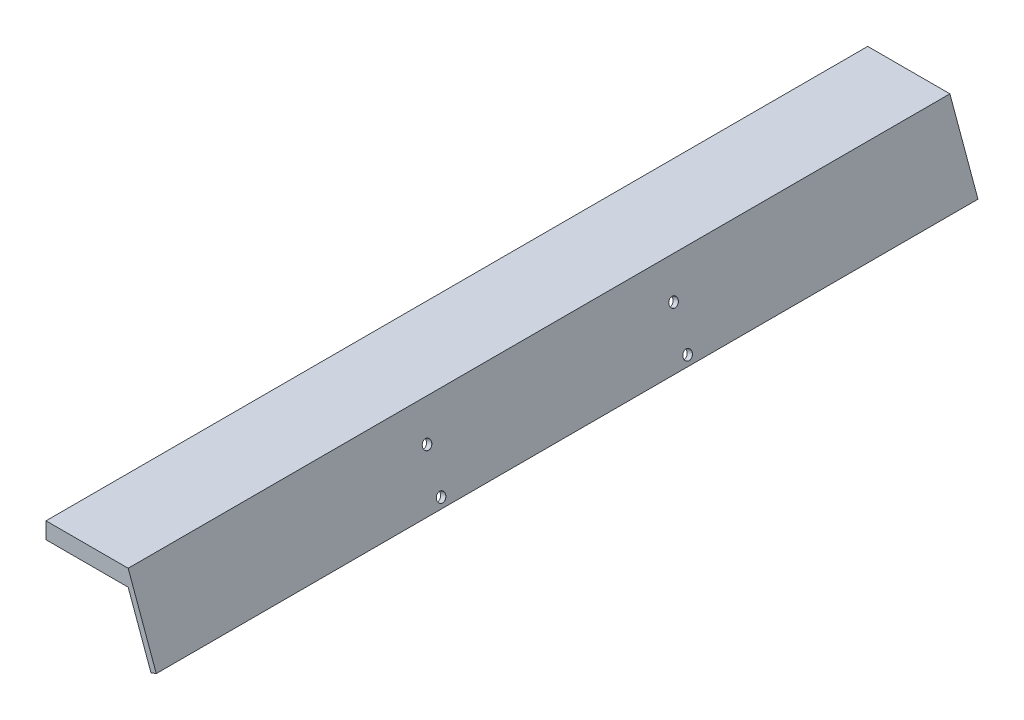
from build123d import *

# Parameters (mm, degrees)
BOSS_EXTRUDE6_DEPTH            = 500
M5_CLEARANCE_HOLE1_D           = 5.5
M5_CLEARANCE_HOLE1_CSINK_D     = 5.55
M5_CLEARANCE_HOLE1_CSINK_ANGLE = 90


with BuildPart() as part:
    # Sketch4 → Boss-Extrude6 (new body)
    with BuildSketch(Plane.XY):
        Polygon((0, 0), (50, 0), (67.101007166, -46.984631039), (63.887069118, -48.154408824), (50, -10), (0, -10), align=None)
    extrude(amount=BOSS_EXTRUDE6_DEPTH)

    # M5 Clearance Hole1 (through all)
    with Locations(Plane(origin=(44.151111078, 16.069690242, 0), x_dir=(0, 0, -1), z_dir=(0.939692621, 0.342020143, 0))):
        with Locations((-325, -37.141900038), (-325, -62.141900038), (-175, -62.141900038), (-175, -37.141900038)):
            CounterSinkHole(M5_CLEARANCE_HOLE1_D / 2, M5_CLEARANCE_HOLE1_CSINK_D / 2, counter_sink_angle=M5_CLEARANCE_HOLE1_CSINK_ANGLE)


solid = part.part
